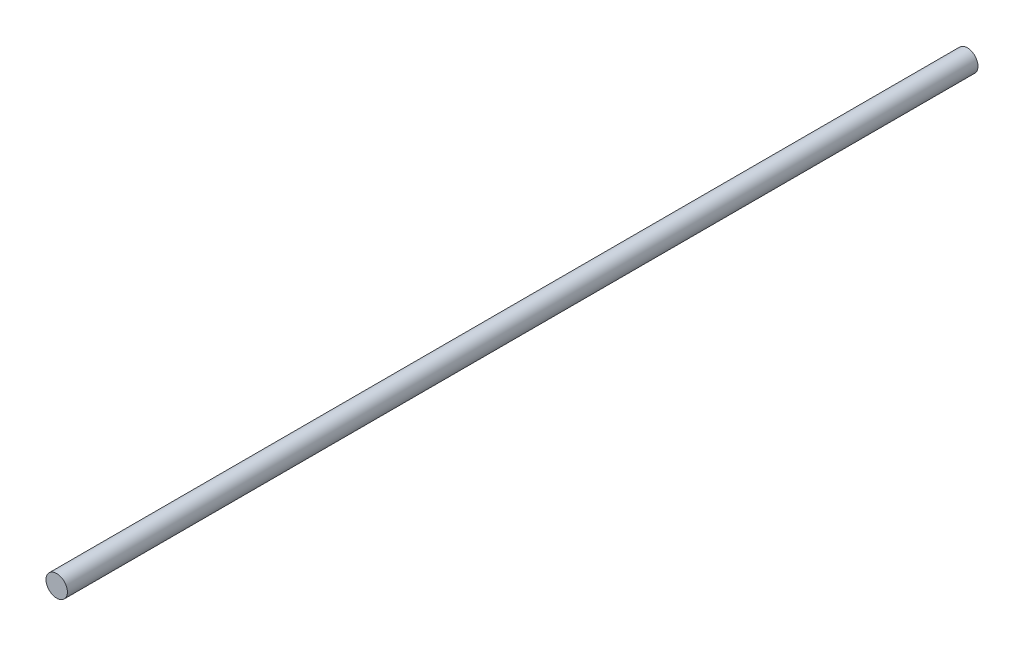
from build123d import *

# Parameters (mm, degrees)
SKETCH2_R           = 3.175
BOSS_EXTRUDE2_DEPTH = 270


with BuildPart() as part:
    # Sketch2 → Boss-Extrude2 (new body)
    with BuildSketch(Plane.XY):
        Circle(SKETCH2_R)
    extrude(amount=BOSS_EXTRUDE2_DEPTH)


solid = part.part
